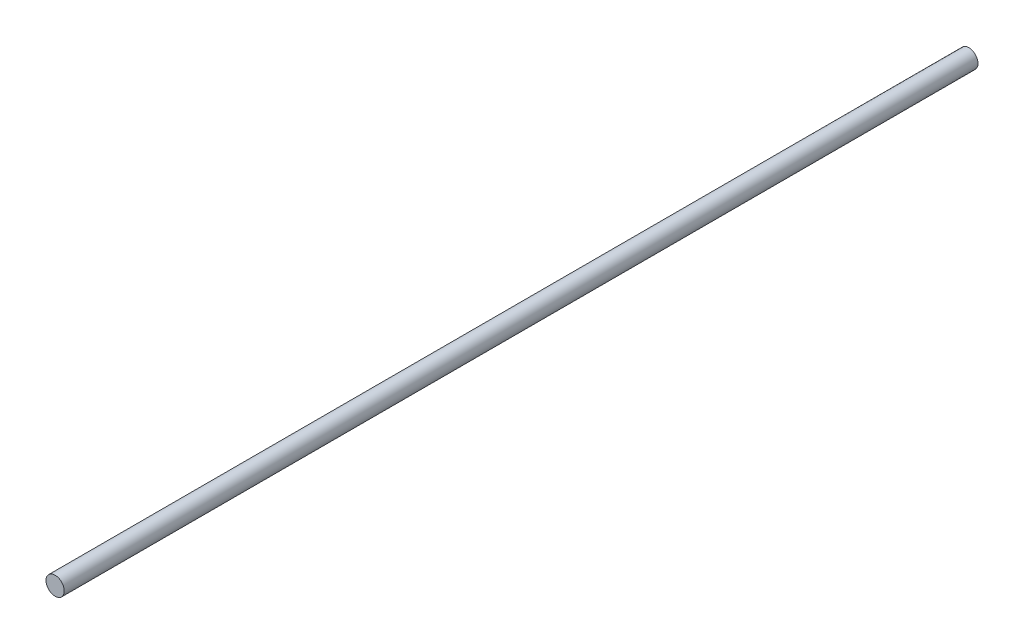
from build123d import *

# Parameters (mm, degrees)
SKETCH1_R           = 1
BOSS_EXTRUDE1_DEPTH = 100


with BuildPart() as part:
    # Sketch1 → Boss-Extrude1 (new body)
    with BuildSketch(Plane.XY):
        Circle(SKETCH1_R)
    extrude(amount=BOSS_EXTRUDE1_DEPTH)


solid = part.part
